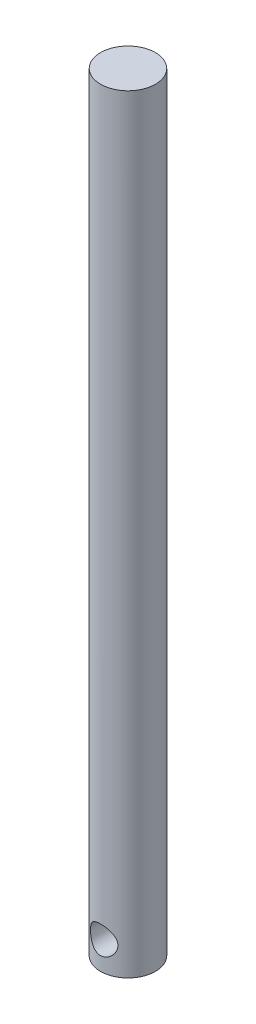
from build123d import *

# Parameters (mm, degrees)
SKETCH1_R               = 6.35
BOSS_EXTRUDE1_DEPTH     = 177.8
SKETCH2_R               = 3.175
CUT_EXTRUDE1_DEPTH      = 7.35
CUT_EXTRUDE1_DEPTH_BACK = 7.35


with BuildPart() as part:
    # Sketch1 → Boss-Extrude1 (new body)
    with BuildSketch(Plane(origin=(0, 0, 0), x_dir=(1, 0, 0), z_dir=(0, 1, 0))):
        with Locations(Location((0, 0, 0), (0, 0, 270))):  # turned: the seam where the file's is
            Circle(SKETCH1_R)
    extrude(amount=BOSS_EXTRUDE1_DEPTH)

    # Sketch2 → Cut-Extrude1 (cut, two sides)
    with BuildSketch(Plane.XY) as cut_extrude1_sk:
        with Locations((0, 6.35)):
            Circle(SKETCH2_R)
    extrude(amount=CUT_EXTRUDE1_DEPTH, mode=Mode.SUBTRACT)
    extrude(cut_extrude1_sk.sketch, amount=-CUT_EXTRUDE1_DEPTH_BACK, mode=Mode.SUBTRACT)


solid = part.part
